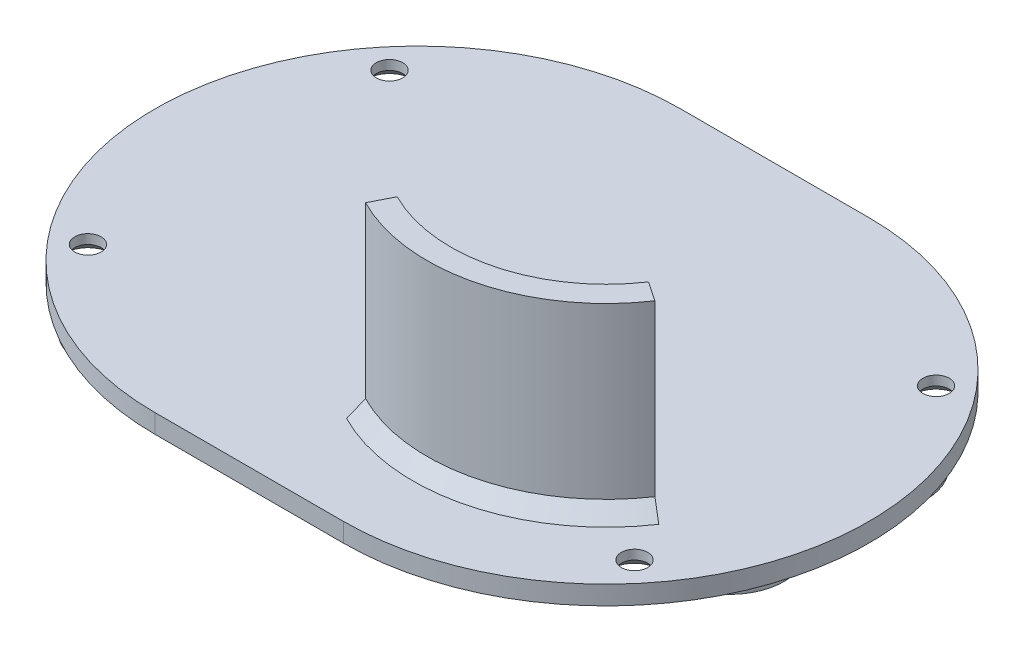
from build123d import *

# Parameters (mm, degrees)
BOSS_EXTRUDE1_DEPTH                                  = 2
EXTRUDE_THIN2_DEPTH                                  = 19.5
CHAMFER1_SIZE                                        = 1.5
CSK_FOR_ST2_2_CROSS_RECESSED_CTSK_HEAD_T_D           = 2.8
CSK_FOR_ST2_2_CROSS_RECESSED_CTSK_HEAD_T_DEPTH       = 7.5
CSK_FOR_ST2_2_CROSS_RECESSED_CTSK_HEAD_T_CSINK_D     = 4.8
CSK_FOR_ST2_2_CROSS_RECESSED_CTSK_HEAD_T_CSINK_ANGLE = 90
CSK_FOR_ST2_2_CROSS_RECESSED_CTSK_HEAD_T_TIP         = 0.841204867
SKETCH4_R                                            = 5.75
SKETCH4_R_2                                          = 4.25
EXTRUDE_THIN1_DEPTH                                  = 0.5


with BuildPart() as part:
    # Sketch1 → Boss-Extrude1 (new body)
    with BuildSketch(Plane.XZ.offset(-2)):
        with BuildLine():
            Line((0, -27.9), (20, -27.9))
            ThreePointArc((20, -27.9), (47.9, 0), (20, 27.9))
            Line((20, 27.9), (0, 27.9))
            ThreePointArc((0, 27.9), (-27.9, 0), (0, -27.9))
        make_face()
    extrude(amount=BOSS_EXTRUDE1_DEPTH)

    # Sketch8 → Extrude-Thin2 (add)
    with BuildSketch(Plane(origin=(0, 2, 0), x_dir=(1, 0, 0), z_dir=(0, 1, 0))):
        with BuildLine():
            ThreePointArc((33.69302994, -9.206026887), (24.155985639, -15.968023778), (12.53247907, -14.71346768))
            Line((12.53247907, -14.71346768), (11.401036505, -16.942780965))
            ThreePointArc((11.401036505, -16.942780965), (24.785680433, -18.38742132), (35.767731446, -10.600879446))
            Line((35.767731446, -10.600879446), (33.69302994, -9.206026887))
        make_face()
    extrude(amount=EXTRUDE_THIN2_DEPTH)

    # Chamfer1
    chamfer1_edges = [part.edges().sort_by_distance(p)[0] for p in [
        (24.155985639, 2, 15.968023778),
        (24.785680433, 2, 18.38742132),
    ]]
    chamfer(chamfer1_edges, length=CHAMFER1_SIZE)

    # CSK for ST2.2 Cross recessed CTSK head tapping screws1
    with Locations(Plane(origin=(0, 0, 0), x_dir=(-1, 0, 0), z_dir=(0, -1, 0))):
        with Locations((-39, 16), (-39, -16), (19, -16), (19, 16)):
            CounterSinkHole(CSK_FOR_ST2_2_CROSS_RECESSED_CTSK_HEAD_T_D / 2, CSK_FOR_ST2_2_CROSS_RECESSED_CTSK_HEAD_T_CSINK_D / 2, depth=CSK_FOR_ST2_2_CROSS_RECESSED_CTSK_HEAD_T_DEPTH, counter_sink_angle=CSK_FOR_ST2_2_CROSS_RECESSED_CTSK_HEAD_T_CSINK_ANGLE)
            with Locations((0, 0, -(CSK_FOR_ST2_2_CROSS_RECESSED_CTSK_HEAD_T_DEPTH + CSK_FOR_ST2_2_CROSS_RECESSED_CTSK_HEAD_T_TIP / 2))):  # 118° drill point
                Cone(0, CSK_FOR_ST2_2_CROSS_RECESSED_CTSK_HEAD_T_D / 2, CSK_FOR_ST2_2_CROSS_RECESSED_CTSK_HEAD_T_TIP, mode=Mode.SUBTRACT)

    # Sketch4 → Extrude-Thin1 (add)
    with BuildSketch(Plane.XZ):
        with Locations((-11, 19.052558883)):
            Circle(SKETCH4_R)
        with Locations((-11, 19.052558883)):
            Circle(SKETCH4_R_2, mode=Mode.SUBTRACT)
        with Locations((-11, -19.052558883)):
            Circle(SKETCH4_R)
        with Locations((-11, -19.052558883)):
            Circle(SKETCH4_R_2, mode=Mode.SUBTRACT)
        with Locations((40.673237657, 7.524443153)):
            Circle(SKETCH4_R)
        with Locations((40.673237657, 7.524443153)):
            Circle(SKETCH4_R_2, mode=Mode.SUBTRACT)
        with Locations((40.673237657, -7.524443153)):
            Circle(SKETCH4_R)
        with Locations((40.673237657, -7.524443153)):
            Circle(SKETCH4_R_2, mode=Mode.SUBTRACT)
    extrude(amount=EXTRUDE_THIN1_DEPTH)


solid = part.part
